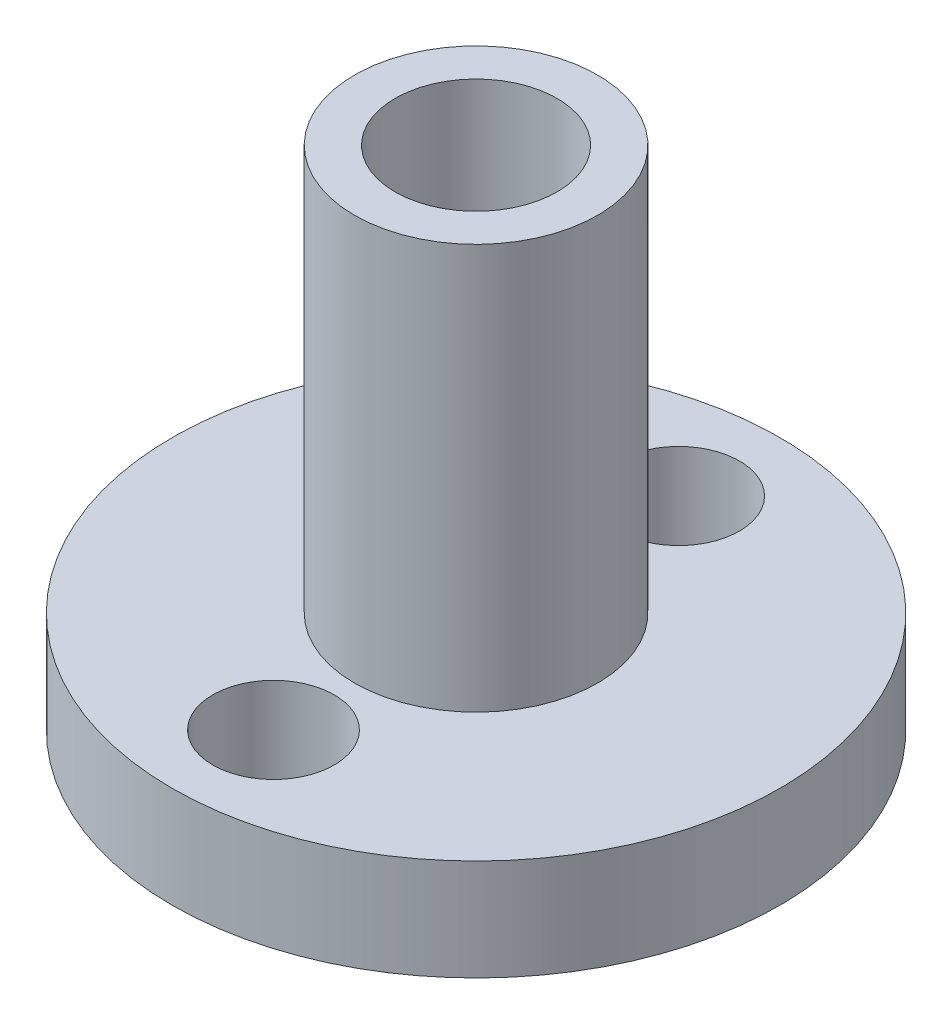
from build123d import *

# Parameters (mm, degrees)
SKETCH1_R           = 15
SKETCH1_R_2         = 3
BOSS_EXTRUDE1_DEPTH = 5
SKETCH2_R           = 6
SKETCH2_R_2         = 4
BOSS_EXTRUDE2_DEPTH = 20


with BuildPart() as part:
    # Sketch1 → Boss-Extrude1 (new body)
    with BuildSketch(Plane(origin=(0, 0, 0), x_dir=(1, 0, 0), z_dir=(0, 1, 0))):
        Circle(SKETCH1_R)
        with Locations((0, 10)):
            Circle(SKETCH1_R_2, mode=Mode.SUBTRACT)
        with Locations((0, -10)):
            Circle(SKETCH1_R_2, mode=Mode.SUBTRACT)
    extrude(amount=BOSS_EXTRUDE1_DEPTH)

    # Sketch2 → Boss-Extrude2 (add)
    with BuildSketch(Plane(origin=(0, 5, 0), x_dir=(1, 0, 0), z_dir=(0, 1, 0))):
        Circle(SKETCH2_R)
        Circle(SKETCH2_R_2, mode=Mode.SUBTRACT)
    extrude(amount=BOSS_EXTRUDE2_DEPTH)


solid = part.part
